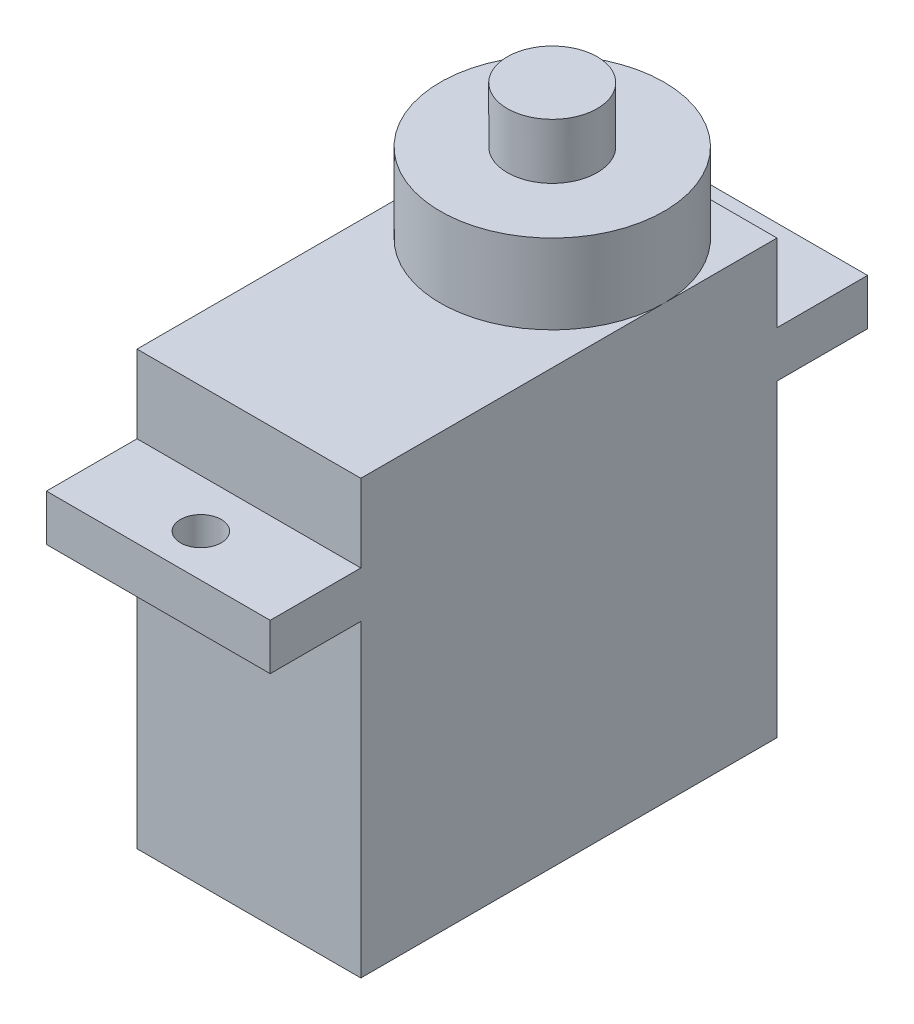
from build123d import *

# Parameters (mm, degrees)
BOSS_EXTRUDE1_DEPTH = 12.1
SKETCH2_R           = 1.1
CUT_EXTRUDE1_DEPTH  = 20.2
SKETCH3_R           = 6.05
BOSS_EXTRUDE3_DEPTH = 4.3
SKETCH4_R           = 2.43
BOSS_EXTRUDE4_DEPTH = 3


with BuildPart() as part:
    # Sketch1 → Boss-Extrude1 (new body)
    with BuildSketch(Plane(origin=(0, 0, 0), x_dir=(0, 0, -1), z_dir=(1, 0, 0))):
        Polygon((0, 0), (22.5, 0), (22.5, 16.7), (27.4, 16.7), (27.4, 19.2), (22.5, 19.2), (22.5, 23.4), (0, 23.4), (0, 19.2), (-4.9, 19.2), (-4.9, 16.7), (0, 16.7), align=None)
    extrude(amount=BOSS_EXTRUDE1_DEPTH)

    # Sketch2 → Cut-Extrude1 (cut, through all)
    with BuildSketch(Plane(origin=(0, 19.2, 0), x_dir=(1, 0, 0), z_dir=(0, 1, 0))):
        with Locations((6.05, -2.6)):
            Circle(SKETCH2_R)
        with Locations((6.05, 25.1)):
            Circle(SKETCH2_R)
    extrude(amount=-CUT_EXTRUDE1_DEPTH, mode=Mode.SUBTRACT)

    # Sketch3 → Boss-Extrude3 (add)
    with BuildSketch(Plane(origin=(0, 23.4, 0), x_dir=(1, 0, 0), z_dir=(0, 1, 0))):
        with Locations((6.05, 16.4)):
            Circle(SKETCH3_R)
    extrude(amount=BOSS_EXTRUDE3_DEPTH)

    # Sketch4 → Boss-Extrude4 (add)
    with BuildSketch(Plane(origin=(0, 27.7, 0), x_dir=(1, 0, 0), z_dir=(0, 1, 0))):
        with Locations((6.05, 16.4)):
            Circle(SKETCH4_R)
    extrude(amount=BOSS_EXTRUDE4_DEPTH)


solid = part.part
